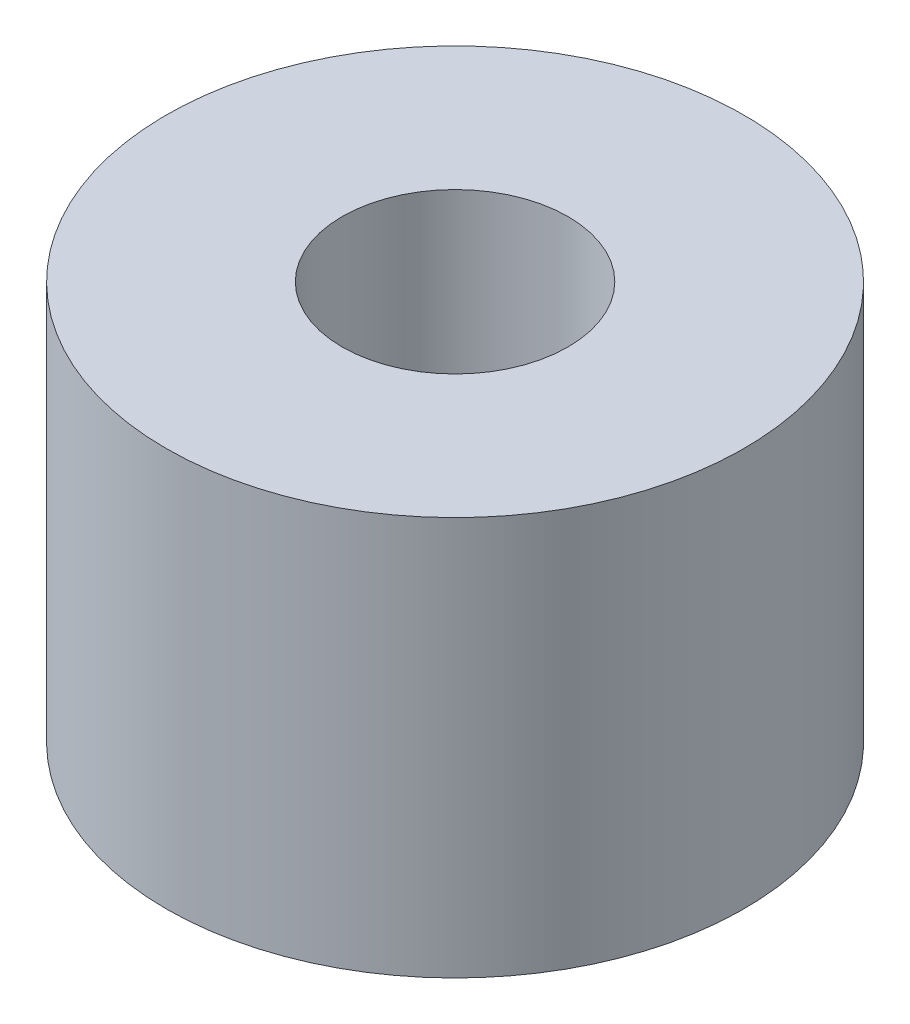
from build123d import *

# Parameters (mm, degrees)
SKETCH1_R           = 8.2804
SKETCH1_R_2         = 3.2385
BOSS_EXTRUDE1_DEPTH = 11.43


with BuildPart() as part:
    # Sketch1 → Boss-Extrude1 (new body)
    with BuildSketch(Plane(origin=(0, 0, 0), x_dir=(1, 0, 0), z_dir=(0, 1, 0))):
        Circle(SKETCH1_R)
        Circle(SKETCH1_R_2, mode=Mode.SUBTRACT)
    extrude(amount=BOSS_EXTRUDE1_DEPTH)


solid = part.part
